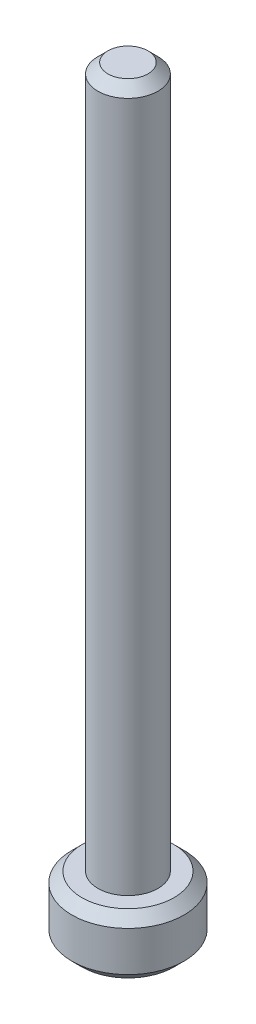
from build123d import *

# Parameters (mm, degrees)
SKETCH1_R           = 2.8
BOSS_EXTRUDE1_DEPTH = 1.5
SKETCH2_R           = 1.5
BOSS_EXTRUDE2_DEPTH = 35
CHAMFER1_SIZE       = 0.5
CHAMFER2_SIZE       = 0.5


with BuildPart() as part:
    # Sketch1 → Boss-Extrude1 (new body, symmetric)
    with BuildSketch(Plane(origin=(0, 0, 0), x_dir=(1, 0, 0), z_dir=(0, 1, 0))):
        Circle(SKETCH1_R)
    extrude(amount=BOSS_EXTRUDE1_DEPTH, both=True)

    # Sketch2 → Boss-Extrude2 (add)
    with BuildSketch(Plane(origin=(0, 1.5, 0), x_dir=(1, 0, 0), z_dir=(0, 1, 0))):
        Circle(SKETCH2_R)
    extrude(amount=BOSS_EXTRUDE2_DEPTH)

    # Chamfer1
    chamfer1_edges = [part.edges().sort_by_distance(p)[0] for p in [
        (-1.5, 36.5, 0),
    ]]
    chamfer(chamfer1_edges, length=CHAMFER1_SIZE)

    # Chamfer2
    chamfer2_edges = [part.edges().sort_by_distance(p)[0] for p in [
        (-2.8, -1.5, 0),
        (-2.8, 1.5, 0),
    ]]
    chamfer(chamfer2_edges, length=CHAMFER2_SIZE)


solid = part.part
